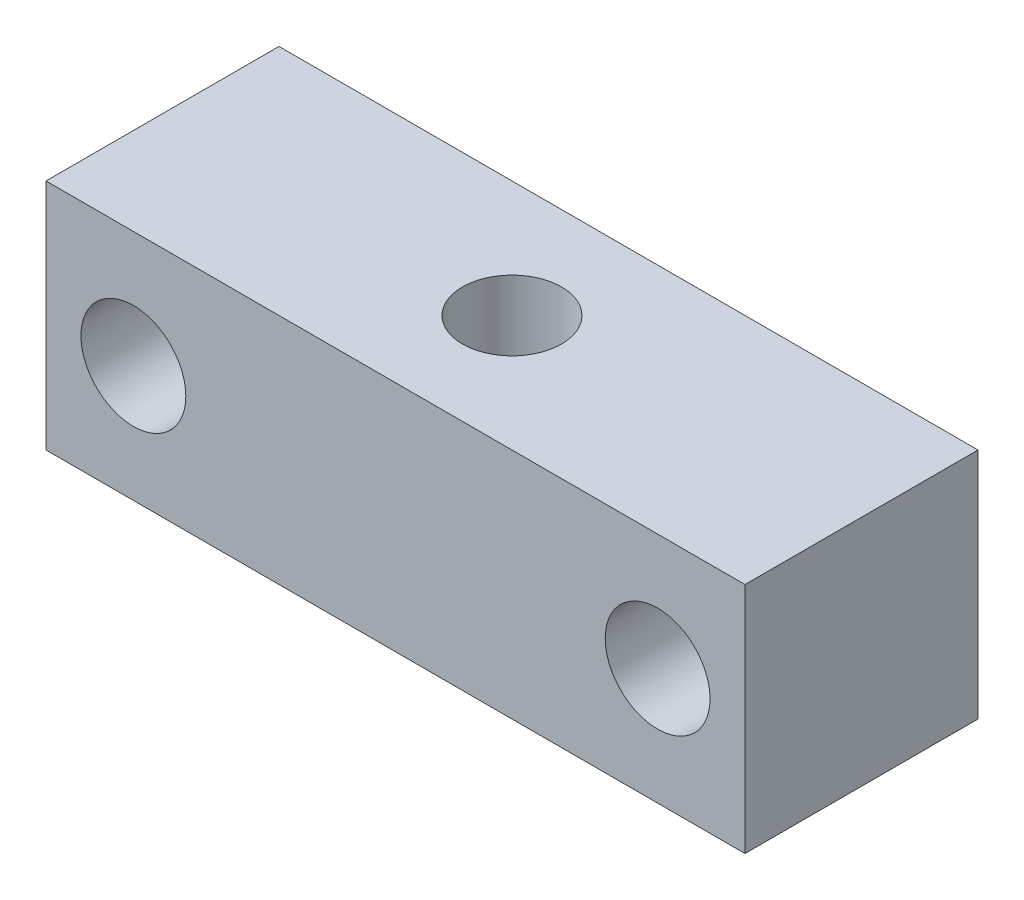
from build123d import *

# Parameters (mm, degrees)
SKETCH_1_W              = 60
SKETCH_1_H              = 20
SKETCH_1_R              = 4.5
EXTRUDE_1_DEPTH         = 20
HOLE_WIZARD_M10_1_D     = 8.5
HOLE_WIZARD_M10_1_DEPTH = 24.5
HOLE_WIZARD_M10_1_TIP   = 2.553657631


with BuildPart() as part:
    # 草图1 → 凸台-拉伸1 (new body)
    with BuildSketch(Plane.XY):
        Rectangle(SKETCH_1_W, SKETCH_1_H)
        with Locations((-22.5, 0)):
            Circle(SKETCH_1_R, mode=Mode.SUBTRACT)
        with Locations((22.5, 0)):
            Circle(SKETCH_1_R, mode=Mode.SUBTRACT)
    extrude(amount=EXTRUDE_1_DEPTH)

    # M10 螺纹孔1
    with Locations(Plane(origin=(0, 10, 10), x_dir=(0, 0, 1), z_dir=(0, 1, 0))):
        with Locations((0, 0)):
            Hole(HOLE_WIZARD_M10_1_D / 2, depth=HOLE_WIZARD_M10_1_DEPTH)
            with Locations((0, 0, -(HOLE_WIZARD_M10_1_DEPTH + HOLE_WIZARD_M10_1_TIP / 2))):  # 118° drill point
                Cone(0, HOLE_WIZARD_M10_1_D / 2, HOLE_WIZARD_M10_1_TIP, mode=Mode.SUBTRACT)


solid = part.part
